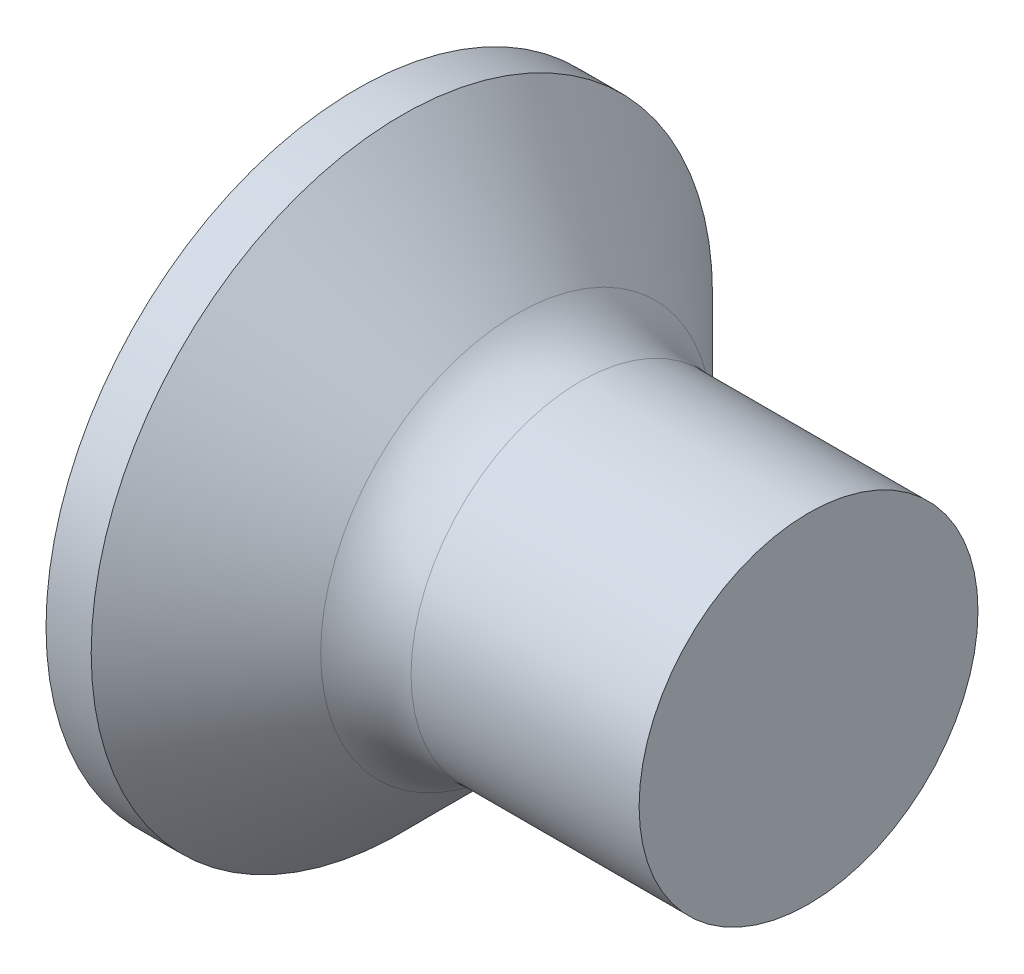
from build123d import *

# Parameters (mm, degrees)
FILLET1_R    = 0.8
SKETCH3_W    = 0.74
SKETCH3_H    = 3
SKETCH4_W    = 0.74
SKETCH4_H    = 0.99570227
RECPAT_COUNT = 2
RECPAT_ANGLE = 90


with BuildPart() as part:
    # BodySke → Base-Revolve (revolve)
    with BuildSketch(Plane.XY):
        Polygon((0, 0), (0, 2.75), (0.4, 2.75), (1.65, 1.5), (4, 1.5), (4, 0), align=None)
    revolve(axis=Axis((-6.35, 0, 0), (1, 0, 0)))

    # Fillet1
    fillet1_edges = [part.edges().sort_by_distance(p)[0] for p in [
        (1.65, -1.5, 0),
    ]]
    fillet(fillet1_edges, radius=FILLET1_R)

    # Sketch3 → Recess section 0
    with BuildSketch(Plane.ZY):
        Rectangle(SKETCH3_W, SKETCH3_H)
    # Sketch4 → Recess section 1
    with BuildSketch(Plane.ZY.offset(-2.01)):
        Rectangle(SKETCH4_W, SKETCH4_H)
    recess = loft(mode=Mode.SUBTRACT)

    # RecPat: Recess ×2 about axis
    recpat_axis = Axis((0, 0, 0), (1, 0, 0))
    for i in range(1, RECPAT_COUNT):
        add(recess.rotate(recpat_axis, i * RECPAT_ANGLE / (RECPAT_COUNT - 1)), mode=Mode.SUBTRACT)

    # RecCorSke → RecessCore (revolve, cut)
    with BuildSketch(Plane.XY):
        Polygon((0, 0), (0, 0.696552892), (2.01, 0.556), (2.190655351, 0), align=None)
    revolve(axis=Axis((-3.175, 0, 0), (1, 0, 0)), mode=Mode.SUBTRACT)


solid = part.part
